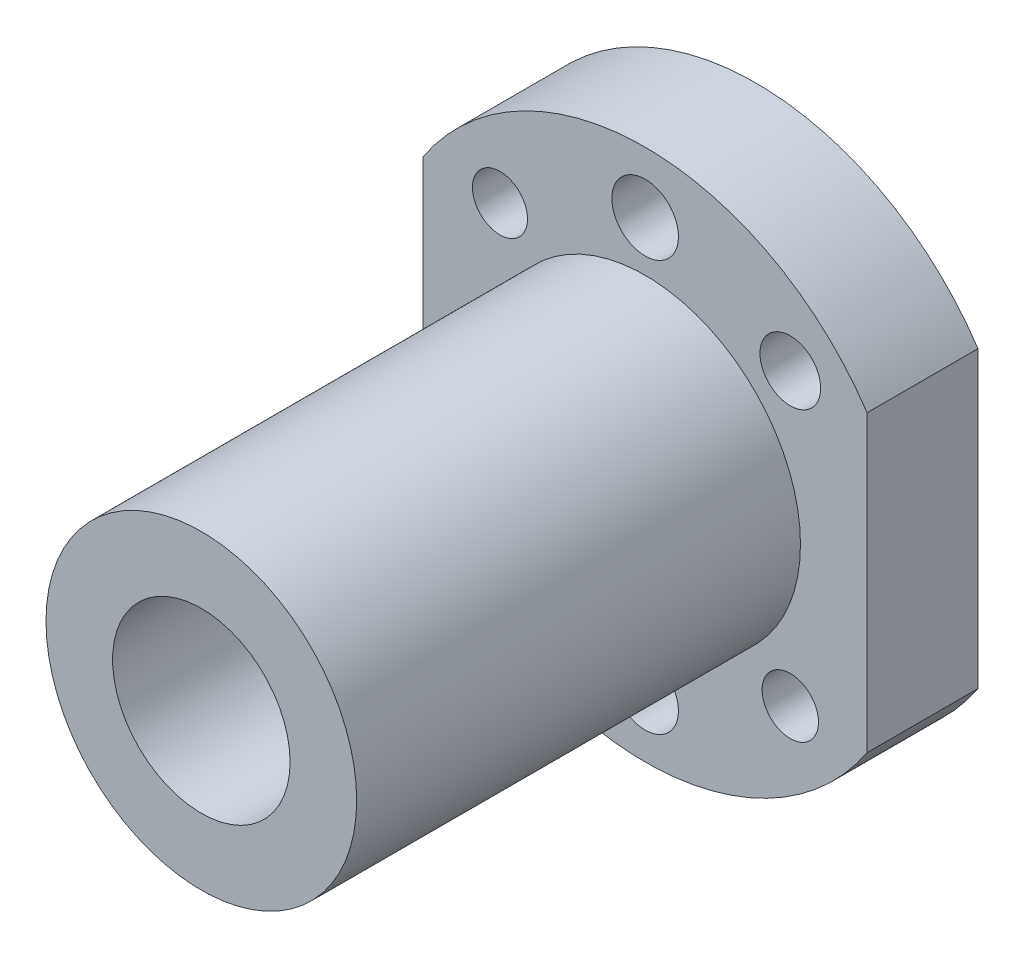
from build123d import *

# Parameters (mm, degrees)
SKETCH_1_R          = 24
EXTRUDE_1_DEPTH     = 10
SKETCH_2_R          = 14
EXTRUDE_2_DEPTH     = 40
SKETCH_3_R          = 8
CUT_EXTRUDE_1_DEPTH = 50
CUT_EXTRUDE_2_DEPTH = 10
SKETCH_5_R          = 3
SKETCH_5_R_2        = 2.542834368
SKETCH_5_R_3        = 3.082379743
SKETCH_5_R_4        = 2.48129437
SKETCH_5_R_5        = 2.732701735
CUT_EXTRUDE_3_DEPTH = 10


with BuildPart() as part:
    # 草图1 → 凸台-拉伸1 (new body)
    with BuildSketch(Plane.XY):
        Circle(SKETCH_1_R)
    extrude(amount=EXTRUDE_1_DEPTH)

    # 草图2 → 凸台-拉伸2 (add)
    with BuildSketch(Plane.XY.offset(10)):
        Circle(SKETCH_2_R)
    extrude(amount=EXTRUDE_2_DEPTH)

    # 草图3 → 切除-拉伸1 (cut)
    with BuildSketch(Plane.XY.offset(50)):
        Circle(SKETCH_3_R)
    extrude(amount=-CUT_EXTRUDE_1_DEPTH, mode=Mode.SUBTRACT)

    # 草图4 → 切除-拉伸2 (cut)
    with BuildSketch(Plane(origin=(0, 0, 0), x_dir=(-1, 0, 0), z_dir=(0, 0, -1))):
        with BuildLine():
            Line((-20, 13.266499161), (-20, -13.266499161))
            ThreePointArc((-20, -13.266499161), (-24, 0), (-20, 13.266499161))
        make_face()
        with BuildLine():
            Line((20, 13.266499161), (20, -13.266499161))
            ThreePointArc((20, -13.266499161), (24, 0), (20, 13.266499161))
        make_face()
    extrude(amount=-CUT_EXTRUDE_2_DEPTH, mode=Mode.SUBTRACT)

    # 草图5 → 切除-拉伸3 (cut)
    with BuildSketch(Plane(origin=(0, 0, 0), x_dir=(-1, 0, 0), z_dir=(0, 0, -1))):
        with Locations((0, 18.503142877)):
            Circle(SKETCH_5_R)
        with Locations((-13.083697802, -13.083697802)):
            Circle(SKETCH_5_R_2)
        with Locations((13.083697802, -13.083697802)):
            Circle(SKETCH_5_R_3)
        with Locations((13.083697802, 13.083697802)):
            Circle(SKETCH_5_R_4)
        with Locations((-13.083697802, 13.083697802)):
            Circle(SKETCH_5_R_5)
        with Locations((0, -18.503142877)):
            Circle(SKETCH_5_R)
    extrude(amount=-CUT_EXTRUDE_3_DEPTH, mode=Mode.SUBTRACT)


solid = part.part
